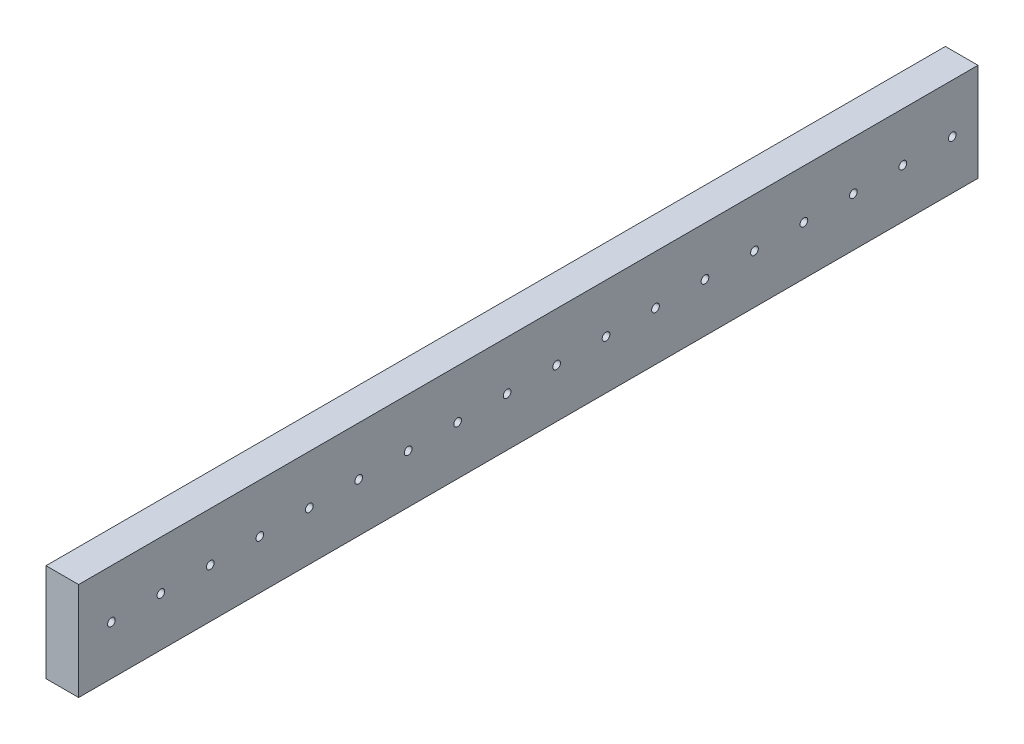
from build123d import *

# Parameters (mm, degrees)
CROQUIS2_W              = 25.4
CROQUIS2_H              = 76.2
SALIENTE_EXTRUIR1_DEPTH = 700
CROQUIS3_R              = 3
CORTAR_EXTRUIR1_DEPTH   = 26.4


with BuildPart() as part:
    # Croquis2 → Saliente-Extruir1 (new body)
    with BuildSketch(Plane.XY):
        Rectangle(CROQUIS2_W, CROQUIS2_H)
    extrude(amount=-SALIENTE_EXTRUIR1_DEPTH)

    # Croquis3 → Cortar-Extruir1 (cut, through all)
    with BuildSketch(Plane.ZY.offset(12.7)):
        with Locations((-680, 0)):
            Circle(CROQUIS3_R)
        with Locations((-641.5, 0)):
            Circle(CROQUIS3_R)
        with Locations((-603, 0)):
            Circle(CROQUIS3_R)
        with Locations((-564.5, 0)):
            Circle(CROQUIS3_R)
        with Locations((-526, 0)):
            Circle(CROQUIS3_R)
        with Locations((-487.5, 0)):
            Circle(CROQUIS3_R)
        with Locations((-449, 0)):
            Circle(CROQUIS3_R)
        with Locations((-410.5, 0)):
            Circle(CROQUIS3_R)
        with Locations((-372, 0)):
            Circle(CROQUIS3_R)
        with Locations((-333.5, 0)):
            Circle(CROQUIS3_R)
        with Locations((-295, 0)):
            Circle(CROQUIS3_R)
        with Locations((-256.5, 0)):
            Circle(CROQUIS3_R)
        with Locations((-218, 0)):
            Circle(CROQUIS3_R)
        with Locations((-179.5, 0)):
            Circle(CROQUIS3_R)
        with Locations((-141, 0)):
            Circle(CROQUIS3_R)
        with Locations((-102.5, 0)):
            Circle(CROQUIS3_R)
        with Locations((-64, 0)):
            Circle(CROQUIS3_R)
        with Locations((-25.5, 0)):
            Circle(CROQUIS3_R)
    extrude(amount=-CORTAR_EXTRUIR1_DEPTH, mode=Mode.SUBTRACT)


solid = part.part
